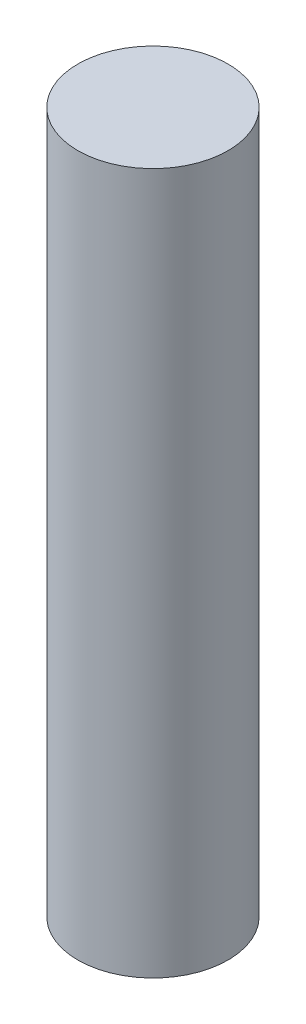
from build123d import *

# Parameters (mm, degrees)
SKETCH_1_R      = 7.5
EXTRUDE_1_DEPTH = 70


with BuildPart() as part:
    # 草图1 → 凸台-拉伸1 (new body)
    with BuildSketch(Plane(origin=(0, 0, 0), x_dir=(1, 0, 0), z_dir=(0, 1, 0))):
        Circle(SKETCH_1_R)
    extrude(amount=EXTRUDE_1_DEPTH)


solid = part.part
